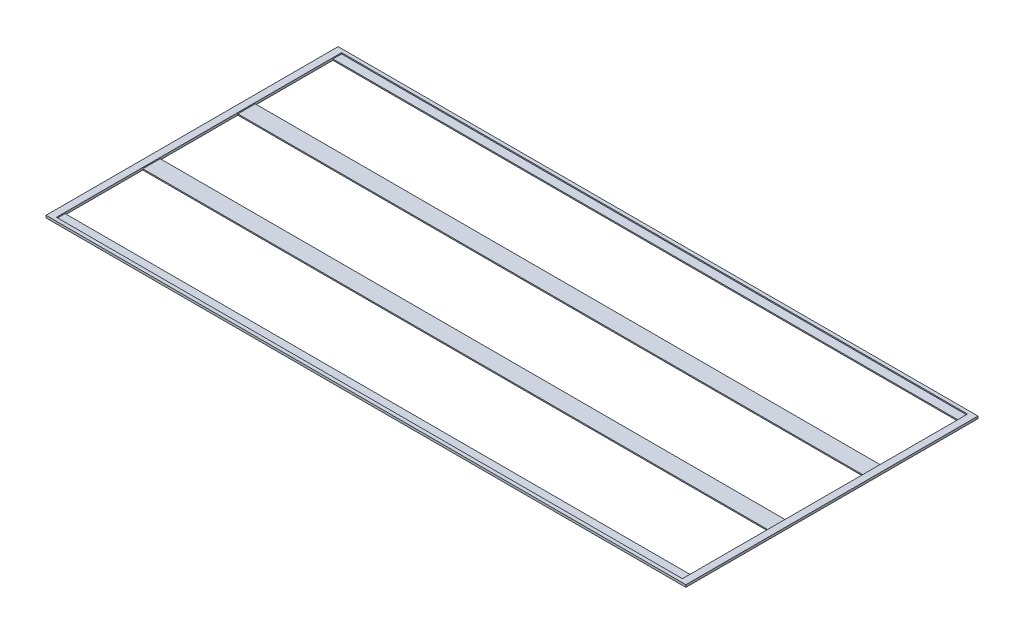
from build123d import *

# Parameters (mm, degrees)
SKETCH1_W           = 1080
SKETCH1_H           = 492
BOSS_EXTRUDE1_DEPTH = 2
SKETCH4_W           = 1104
SKETCH4_H           = 504.01209321
SKETCH4_W_2         = 1080
SKETCH4_H_2         = 492
BOSS_EXTRUDE3_DEPTH = 4
SKETCH5_W           = 1080
SKETCH5_H           = 134
CUT_EXTRUDE2_DEPTH  = 4
LPATTERN2_COUNT     = 3
LPATTERN2_PITCH     = 164


with BuildPart() as part:
    # Sketch1 → Boss-Extrude1 (new body)
    with BuildSketch(Plane(origin=(0, 0, 0), x_dir=(1, 0, 0), z_dir=(0, 1, 0))):
        Rectangle(SKETCH1_W, SKETCH1_H)
    extrude(amount=BOSS_EXTRUDE1_DEPTH)

    # Sketch4 → Boss-Extrude3 (add)
    with BuildSketch(Plane(origin=(0, 0, 0), x_dir=(1, 0, 0), z_dir=(0, 1, 0))):
        Rectangle(SKETCH4_W, SKETCH4_H)
        Rectangle(SKETCH4_W_2, SKETCH4_H_2, mode=Mode.SUBTRACT)
    extrude(amount=BOSS_EXTRUDE3_DEPTH)

    # Sketch5 → Cut-Extrude2 (cut)
    with BuildSketch(Plane(origin=(0, 2, 0), x_dir=(1, 0, 0), z_dir=(0, 1, 0))):
        with Locations((0, 164)):
            Rectangle(SKETCH5_W, SKETCH5_H)
    cut_extrude2 = extrude(amount=-CUT_EXTRUDE2_DEPTH, mode=Mode.SUBTRACT)

    # LPattern2: Cut-Extrude2 ×3
    with Locations(*[(0, 0, i * LPATTERN2_PITCH) for i in range(1, LPATTERN2_COUNT)]):
        add(cut_extrude2, mode=Mode.SUBTRACT)


solid = part.part
